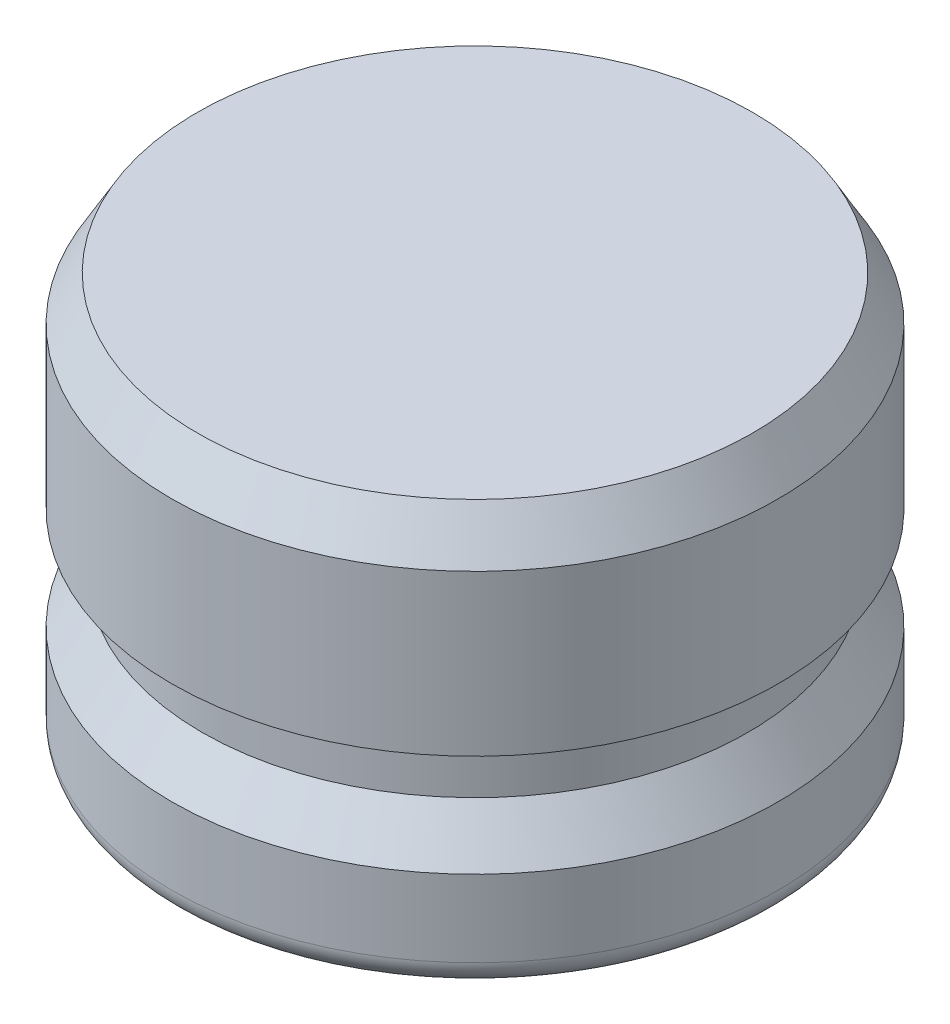
from build123d import *

# Parameters (mm, degrees)
FILLET1_R      = 0.79375
CHAMFER1_SIZE  = 0.79375
CHAMFER1_SIZE2 = 1.374815329


with BuildPart() as part:
    # Sketch1 → Revolve1 (revolve)
    with BuildSketch(Plane.XY):
        Polygon((0, 0), (-9.4234, 0), (-9.4234, 3.175), (-8.4836, 4.572), (-8.4836, 6.35), (-9.4234, 6.35), (-9.4234, 12.7), (0, 12.7), align=None)
    revolve(axis=Axis((0, 0, 0), (0, 1, 0)))

    # Fillet1
    fillet1_edges = [part.edges().sort_by_distance(p)[0] for p in [
        (9.4234, 0, 0),
    ]]
    fillet(fillet1_edges, radius=FILLET1_R)

    # Chamfer1
    chamfer1_edges = [part.edges().sort_by_distance(p)[0] for p in [
        (9.4234, 12.7, 0),
    ]]
    chamfer1_side = [part.faces().sort_by_distance(p)[0] for p in [
        (0, 12.7, 0),
    ]]
    chamfer(chamfer1_edges, length=CHAMFER1_SIZE, length2=CHAMFER1_SIZE2, reference=chamfer1_side[0])


solid = part.part
